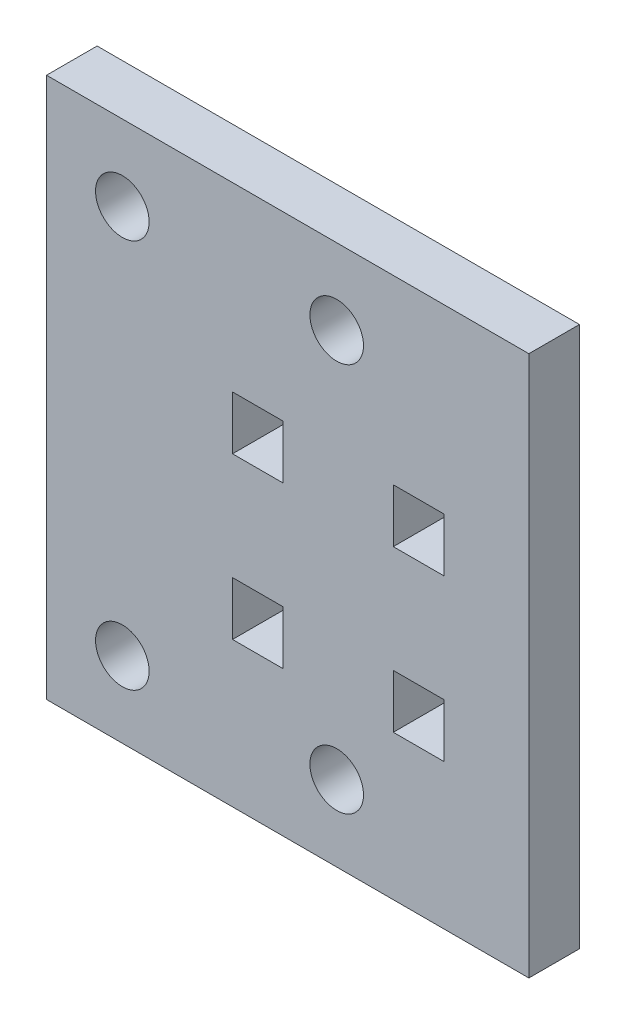
from build123d import *

# Parameters (mm, degrees)
SKETCH1_W           = 57.15
SKETCH1_H           = 64.060512242
SKETCH1_R           = 3.175
SKETCH1_W_2         = 5.9944
SKETCH1_H_2         = 6.35
BOSS_EXTRUDE1_DEPTH = 5.9944


with BuildPart() as part:
    # Sketch1 → Boss-Extrude1 (new body)
    with BuildSketch(Plane(origin=(0, 0, 0), x_dir=(-1, 0, 0), z_dir=(0, 0, 1))):
        with Locations((33.534836058, -1.33105998)):
            Rectangle(SKETCH1_W, SKETCH1_H)
        with Locations((53.129579937, -24.38105998)):
            Circle(SKETCH1_R, mode=Mode.SUBTRACT)
        with Locations((53.129579937, 21.71894002)):
            Circle(SKETCH1_R, mode=Mode.SUBTRACT)
        with Locations((27.729579937, -24.38105998)):
            Circle(SKETCH1_R, mode=Mode.SUBTRACT)
        with Locations((27.729579937, 21.71894002)):
            Circle(SKETCH1_R, mode=Mode.SUBTRACT)
        with Locations((37.076779937, -8.707018437)):
            Rectangle(SKETCH1_W_2, SKETCH1_H_2, mode=Mode.SUBTRACT)
        Polygon((15.029579937, 13.517981563), (21.023979937, 13.517981563), (21.023979937, 7.36894002), (21.023979937, 7.167981563), (15.029579937, 7.167981563), (15.029579937, 7.36894002), align=None, mode=Mode.SUBTRACT)
        with Locations((18.026779937, -8.707018437)):
            Rectangle(SKETCH1_W_2, SKETCH1_H_2, mode=Mode.SUBTRACT)
        Polygon((40.073979937, 7.36894002), (40.073979937, 7.167981563), (34.079579937, 7.167981563), (34.079579937, 7.36894002), (34.079579937, 13.517981563), (40.073979937, 13.517981563), align=None, mode=Mode.SUBTRACT)
    extrude(amount=BOSS_EXTRUDE1_DEPTH)


solid = part.part
